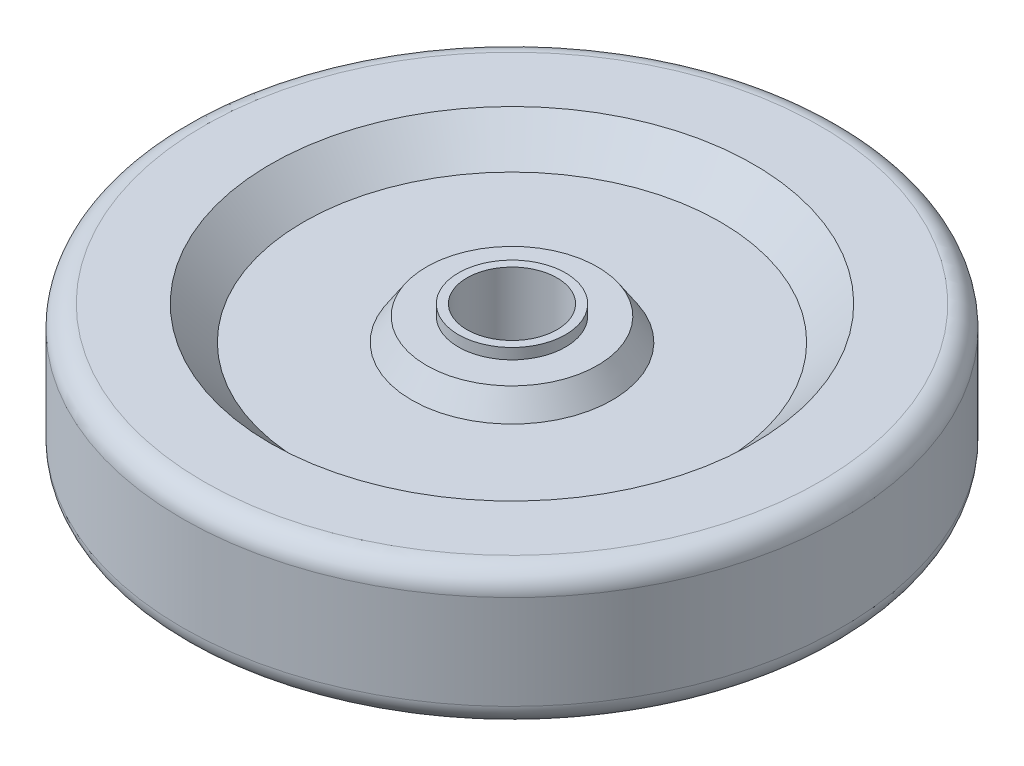
from build123d import *


with BuildPart() as part:
    # Эскиз2 → Повернуть1 (revolve)
    with BuildSketch(Plane(origin=(0, 0, 0), x_dir=(0, 0, -1), z_dir=(1, 0, 0))):
        with BuildLine():
            Line((10.5, 0), (10.5, 32))
            Line((10.5, 32), (12.5, 32))
            Line((12.5, 32), (12.5, 29.5))
            Line((12.5, 29.5), (19.944344329, 29.5))
            Line((19.944344329, 29.5), (23.412925951, 24.236876385))
            Line((23.412925951, 24.236876385), (48.626846206, 24.236876385))
            Line((48.626846206, 24.236876385), (56.389969821, 32))
            Line((56.389969821, 32), (71.909127128, 32))
            ThreePointArc((71.909127128, 32), (75.444661033, 30.535533906), (76.909127128, 27))
            Line((76.909127128, 27), (76.909127128, 5))
            ThreePointArc((76.909127128, 5), (75.444661033, 1.464466094), (71.909127128, 0))
            Line((71.909127128, 0), (56.389969821, 0))
            Line((56.389969821, 0), (48.643821993, 5.968581622))
            Line((48.643821993, 5.968581622), (23.412925951, 5.968581622))
            Line((23.412925951, 5.968581622), (19.944344329, 2.5))
            Line((19.944344329, 2.5), (12.5, 2.5))
            Line((12.5, 2.5), (12.5, 0))
            Line((12.5, 0), (10.5, 0))
        make_face()
    revolve(axis=Axis((0, 76.584186447, 0), (0, -1, 0)))


solid = part.part
